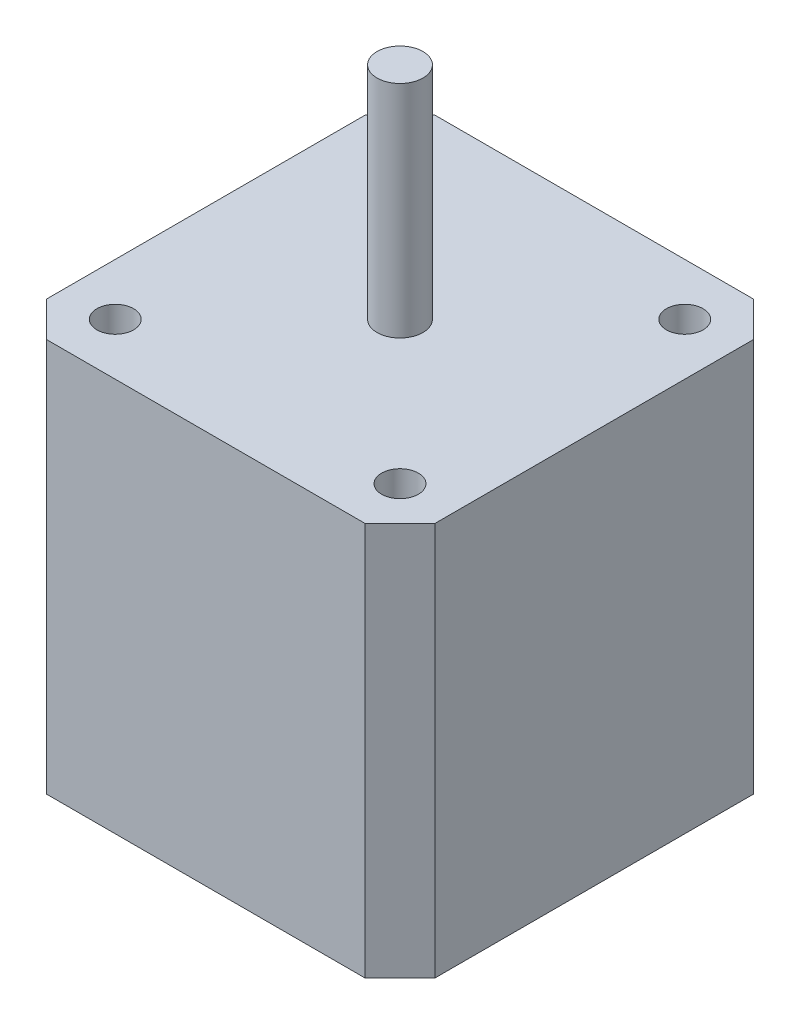
from build123d import *

# Parameters (mm, degrees)
SKETCH1_W           = 42.299999982
SKETCH1_H           = 42.299999982
BOSS_EXTRUDE1_DEPTH = 42.8625
SKETCH2_R           = 2
CUT_EXTRUDE1_DEPTH  = 6.35
CHAMFER1_SIZE       = 3.81
SKETCH3_R           = 2.5
BOSS_EXTRUDE2_DEPTH = 24


with BuildPart() as part:
    # Sketch1 → Boss-Extrude1 (new body)
    with BuildSketch(Plane(origin=(0, 0, 0), x_dir=(1, 0, 0), z_dir=(0, 1, 0))):
        Rectangle(SKETCH1_W, SKETCH1_H)
    extrude(amount=BOSS_EXTRUDE1_DEPTH)

    # Sketch2 → Cut-Extrude1 (cut)
    with BuildSketch(Plane(origin=(0, 42.8625, 0), x_dir=(1, 0, 0), z_dir=(0, 1, 0))):
        with Locations((-15.499999988, -15.499999988)):
            Circle(SKETCH2_R)
        with Locations((-15.499999988, 15.499999988)):
            Circle(SKETCH2_R)
        with Locations((15.499999988, 15.499999988)):
            Circle(SKETCH2_R)
        with Locations((15.499999988, -15.499999988)):
            Circle(SKETCH2_R)
    extrude(amount=-CUT_EXTRUDE1_DEPTH, mode=Mode.SUBTRACT)

    # Chamfer1
    chamfer1_edges = [part.edges().sort_by_distance(p)[0] for p in [
        (-21.149999991, 21.43125, -21.149999991),
        (21.149999991, 21.43125, -21.149999991),
        (21.149999991, 21.43125, 21.149999991),
        (-21.149999991, 21.43125, 21.149999991),
    ]]
    chamfer(chamfer1_edges, length=CHAMFER1_SIZE)

    # Sketch3 → Boss-Extrude2 (add)
    with BuildSketch(Plane(origin=(0, 42.8625, 0), x_dir=(1, 0, 0), z_dir=(0, 1, 0))):
        Circle(SKETCH3_R)
    extrude(amount=BOSS_EXTRUDE2_DEPTH)


solid = part.part
